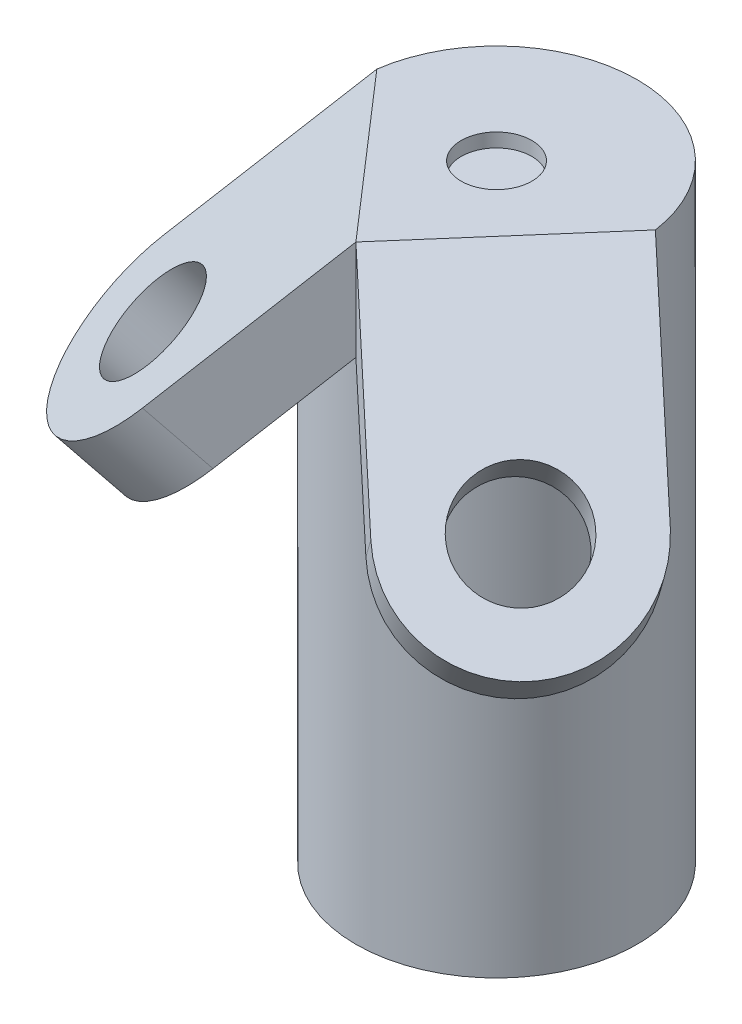
from build123d import *

# Parameters (mm, degrees)
SCHIZZO2_R                   = 25.5
TAGLIO_ESTRUSIONE1_DEPTH     = 10
ESTRUSIONE_ESTRUSIONE1_DEPTH = 51
TAGLIO_ESTRUSIONE2_DEPTH     = 51
SCHIZZO6_R                   = 38.5
TAGLIO_ESTRUSIONE3_DEPTH     = 51


with BuildPart() as part:
    # Schizzo1 → Rivoluzione1 (revolve)
    with BuildSketch(Plane.XY):
        Polygon((0, 439), (101.5, 439), (101.5, 0), (76, 0), (76, 413.5), (0, 413.5), align=None)
    revolve(axis=Axis((0, -167.269578169, 0), (0, 1, 0)))

    # Schizzo2 → Taglio-Estrusione1 (cut)
    with BuildSketch(Plane(origin=(0, 439, 0), x_dir=(1, 0, 0), z_dir=(0, 1, 0))):
        Circle(SCHIZZO2_R)
    extrude(amount=-TAGLIO_ESTRUSIONE1_DEPTH, mode=Mode.SUBTRACT)

    # Schizzo4 → Estrusione-Estrusione1 (add)
    with BuildSketch(Plane(origin=(190.786805103, 252.794995721, 165.848439427), x_dir=(0.656059029, 0, -0.75470958), z_dir=(0.533660262, 0.707106781, 0.463903788))):
        with BuildLine():
            Line((-76.603022393, 263.333642433), (-76.603022393, 108.927930028))
            ThreePointArc((-76.603022393, 108.927930028), (0, 32.324907635), (76.603022393, 108.927930028))
            Line((76.603022393, 108.927930028), (76.603022393, 263.333642433))
            Line((76.603022393, 263.333642433), (-76.603022393, 263.333642433))
        make_face()
    estrusione_estrusione1 = extrude(amount=-ESTRUSIONE_ESTRUSIONE1_DEPTH)

    # Schizzo5 → Taglio-Estrusione2 (cut)
    with BuildSketch(Plane(origin=(190.786805103, 252.794995721, 165.848439427), x_dir=(0.845698956, -0.44620463, -0.292736576), z_dir=(0.533660262, 0.707106781, 0.463903788))):
        with BuildLine():
            Line((-9.31111849, 132.840581346), (-106.745545148, 252.622284978))
            Line((-106.745545148, 252.622284978), (-225.596595186, 155.944882946))
            Line((-225.596595186, 155.944882946), (-128.162168528, 36.163179314))
            ThreePointArc((-128.162168528, 36.163179314), (-20.397942493, 25.076355311), (-9.31111849, 132.840581346))
        make_face()
    taglio_estrusione2 = extrude(amount=TAGLIO_ESTRUSIONE2_DEPTH, mode=Mode.SUBTRACT)

    # Schizzo6 → Taglio-Estrusione3 (cut)
    with BuildSketch(Plane(origin=(190.786805103, 252.794995721, 165.848439427), x_dir=(0.845698956, -0.44620463, -0.292736576), z_dir=(0.533660262, 0.707106781, 0.463903788))):
        with Locations((-68.736643509, 84.50188033)):
            Circle(SCHIZZO6_R)
    taglio_estrusione3 = extrude(amount=-TAGLIO_ESTRUSIONE3_DEPTH, mode=Mode.SUBTRACT)

    # Specchia1: Estrusione-Estrusione1, Taglio-Estrusione2, Taglio-Estrusione3 across plane
    add(estrusione_estrusione1.mirror(Plane(origin=(0, 0, 0), x_dir=(0, 0, 1), z_dir=(1, 0, 0))))
    add(taglio_estrusione2.mirror(Plane(origin=(0, 0, 0), x_dir=(0, 0, 1), z_dir=(1, 0, 0))), mode=Mode.SUBTRACT)
    add(taglio_estrusione3.mirror(Plane(origin=(0, 0, 0), x_dir=(0, 0, 1), z_dir=(1, 0, 0))), mode=Mode.SUBTRACT)


solid = part.part
